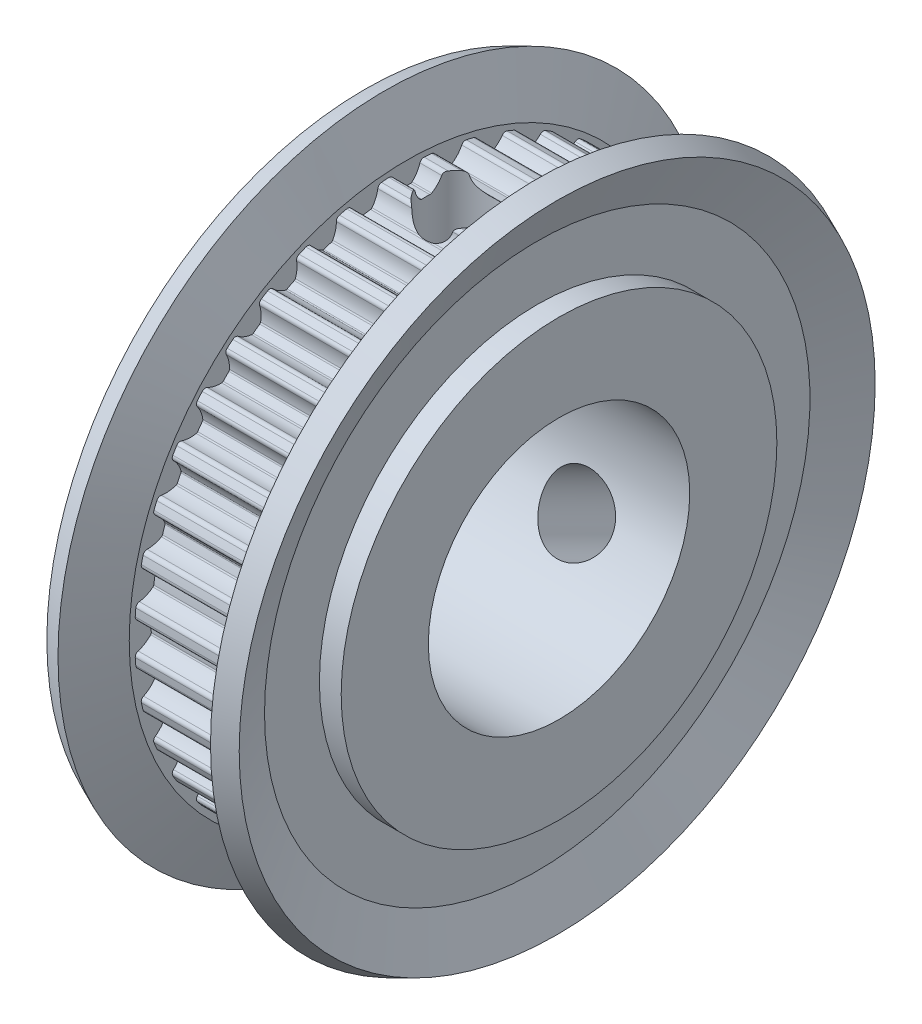
from build123d import *

# Parameters (mm, degrees)
SKETCH2_W           = 9
SKETCH2_H           = 15
CUT_EXTRUDE1_DEPTH  = 5
CUT_EXTRUDE2_DEPTH  = 5
CUT_EXTRUDE3_DEPTH  = 5
CUT_EXTRUDE4_DEPTH  = 5
CUT_EXTRUDE5_DEPTH  = 5
CUT_EXTRUDE6_DEPTH  = 5
CUT_EXTRUDE7_DEPTH  = 5
CUT_EXTRUDE8_DEPTH  = 5
CUT_EXTRUDE9_DEPTH  = 5
CUT_EXTRUDE10_DEPTH = 5
CUT_EXTRUDE11_DEPTH = 5
CUT_EXTRUDE12_DEPTH = 5
CUT_EXTRUDE13_DEPTH = 5
CUT_EXTRUDE14_DEPTH = 5
CUT_EXTRUDE15_DEPTH = 5
CUT_EXTRUDE16_DEPTH = 5
CUT_EXTRUDE17_DEPTH = 5
CUT_EXTRUDE18_DEPTH = 5
CUT_EXTRUDE19_DEPTH = 5
CUT_EXTRUDE20_DEPTH = 5
CUT_EXTRUDE21_DEPTH = 5
CUT_EXTRUDE22_DEPTH = 5
CUT_EXTRUDE23_DEPTH = 5
CUT_EXTRUDE24_DEPTH = 5
CUT_EXTRUDE25_DEPTH = 5
CUT_EXTRUDE26_DEPTH = 5
CUT_EXTRUDE27_DEPTH = 5
CUT_EXTRUDE28_DEPTH = 5
CUT_EXTRUDE29_DEPTH = 5
CUT_EXTRUDE30_DEPTH = 5
CUT_EXTRUDE31_DEPTH = 5
CUT_EXTRUDE32_DEPTH = 5
CUT_EXTRUDE33_DEPTH = 5
CUT_EXTRUDE34_DEPTH = 5
CUT_EXTRUDE35_DEPTH = 5
CUT_EXTRUDE36_DEPTH = 5
CUT_EXTRUDE37_DEPTH = 5
CUT_EXTRUDE38_DEPTH = 5
CUT_EXTRUDE39_DEPTH = 5
CUT_EXTRUDE40_DEPTH = 5
SKETCH43_W          = 1.621
SKETCH43_H          = 6.98


with BuildPart() as part:
    # Sketch1 → Revolve1 (revolve)
    with BuildSketch(Plane.XY):
        Polygon((0, 10), (0, 6), (17, 6), (17, 7), (9, 7), (9, 10), (8, 10), (8, 12.519496019), (8.915136608, 14.59685612), (8, 15), (7, 12.73), (7, 12.48), (2, 12.48), (2, 12.73), (1, 15), (0.084863392, 14.59685612), (1, 12.519496019), (1, 10), align=None)
    revolve(axis=Axis((17, 0, 0), (-1, 0, 0)))

    # Sketch2 → Cut-Revolve1 (revolve, cut)
    with BuildSketch(Plane.XY):
        with Locations((13.5, 7.5)):
            Rectangle(SKETCH2_W, SKETCH2_H)
    revolve(axis=Axis((18, 0, 0), (-1, 0, 0)), mode=Mode.SUBTRACT)

    # Sketch3 → Cut-Extrude1 (cut)
    with BuildSketch(Plane(origin=(2, 0, 0), x_dir=(0, 0, -1), z_dir=(1, 0, 0))):
        with BuildLine():
            Line((0.809176121, 12.45373976), (0.809176121, 16.64))
            Line((0.809176121, 16.64), (-0.809176121, 16.64))
            Line((-0.809176121, 16.64), (-0.809176121, 12.45373976))
            ThreePointArc((-0.809176121, 12.45373976), (-0.689195101, 12.420692836), (-0.615402928, 12.320481761))
            ThreePointArc((-0.615402928, 12.320481761), (-0.472569174, 12.009502865), (-0.254854193, 11.745477217))
            ThreePointArc((-0.254854193, 11.745477217), (-0.222536107, 11.725221856), (-0.18498492, 11.718540036))
            ThreePointArc((-0.18498492, 11.718540036), (1.1e-08, 11.72), (0.184984941, 11.718540036))
            ThreePointArc((0.184984941, 11.718540036), (0.222536138, 11.725221868), (0.254854227, 11.745477248))
            ThreePointArc((0.254854227, 11.745477248), (0.472569186, 12.009502884), (0.615402928, 12.320481761))
            ThreePointArc((0.615402928, 12.320481761), (0.689195101, 12.420692836), (0.809176121, 12.45373976))
        make_face()
    extrude(amount=CUT_EXTRUDE1_DEPTH, mode=Mode.SUBTRACT)

    # Sketch4 → Cut-Extrude2 (cut)
    with BuildSketch(Plane(origin=(2, 0, 0), x_dir=(0, 0, -1), z_dir=(1, 0, 0))):
        with BuildLine():
            Line((-1.148980297, 12.426996591), (-1.803855678, 16.561717021))
            Line((-1.803855678, 16.561717021), (-3.402283318, 16.308550954))
            Line((-3.402283318, 16.308550954), (-2.747407937, 12.173830524))
            ThreePointArc((-2.747407937, 12.173830524), (-2.623734404, 12.15995963), (-2.53517427, 12.072525958))
            ThreePointArc((-2.53517427, 12.072525958), (-2.345451219, 11.78771985), (-2.08911396, 11.561002923))
            ThreePointArc((-2.08911396, 11.561002923), (-2.054025127, 11.546052601), (-2.01589099, 11.545327346))
            ThreePointArc((-2.01589099, 11.545327346), (-1.83341192, 11.575707353), (-1.650476072, 11.603203382))
            ThreePointArc((-1.650476072, 11.603203382), (-1.614432461, 11.615677252), (-1.585680902, 11.640738917))
            ThreePointArc((-1.585680902, 11.640738917), (-1.411949084, 11.935572083), (-1.319521676, 12.265066414))
            ThreePointArc((-1.319521676, 12.265066414), (-1.262314474, 12.375587363), (-1.148980297, 12.426996591))
        make_face()
    extrude(amount=CUT_EXTRUDE2_DEPTH, mode=Mode.SUBTRACT)

    # Sketch5 → Cut-Extrude3 (cut)
    with BuildSketch(Plane(origin=(2, 0, 0), x_dir=(0, 0, -1), z_dir=(1, 0, 0))):
        with BuildLine():
            Line((-3.078845007, 12.094259524), (-4.372470564, 16.075629604))
            Line((-4.372470564, 16.075629604), (-5.911615009, 15.575531258))
            Line((-5.911615009, 15.575531258), (-4.617989452, 11.594161178))
            ThreePointArc((-4.617989452, 11.594161178), (-4.49366866, 11.59980786), (-4.392521208, 11.527304499))
            ThreePointArc((-4.392521208, 11.527304499), (-4.160580471, 11.275684051), (-3.871932808, 11.091858367))
            ThreePointArc((-3.871932808, 11.091858367), (-3.834937231, 11.082581212), (-3.797159134, 11.087830379))
            ThreePointArc((-3.797159134, 11.087830379), (-3.621679164, 11.146382374), (-3.445296887, 11.202157353))
            ThreePointArc((-3.445296887, 11.202157353), (-3.411648376, 11.220116111), (-3.387171304, 11.249366961))
            ThreePointArc((-3.387171304, 11.249366961), (-3.261700482, 11.567747885), (-3.221955278, 11.907644426))
            ThreePointArc((-3.221955278, 11.907644426), (-3.182741677, 12.025753857), (-3.078845007, 12.094259524))
        make_face()
    extrude(amount=CUT_EXTRUDE3_DEPTH, mode=Mode.SUBTRACT)

    # Sketch6 → Cut-Extrude4 (cut)
    with BuildSketch(Plane(origin=(2, 0, 0), x_dir=(0, 0, -1), z_dir=(1, 0, 0))):
        with BuildLine():
            Line((-4.932898334, 11.463721648), (-6.833420713, 15.193706834))
            Line((-6.833420713, 15.193706834), (-8.275383118, 14.458990291))
            Line((-8.275383118, 14.458990291), (-6.37486074, 10.729005105))
            ThreePointArc((-6.37486074, 10.729005105), (-6.252953879, 10.754030324), (-6.141709696, 10.698242547))
            ThreePointArc((-6.141709696, 10.698242547), (-5.873262424, 10.486003489), (-5.55941182, 10.349595447))
            ThreePointArc((-5.55941182, 10.349595447), (-5.521420453, 10.346219893), (-5.484928618, 10.35731423))
            ThreePointArc((-5.484928618, 10.35731423), (-5.320768648, 10.442596468), (-5.155283058, 10.525277032))
            ThreePointArc((-5.155283058, 10.525277032), (-5.124858184, 10.548278474), (-5.105258307, 10.580998256))
            ThreePointArc((-5.105258307, 10.580998256), (-5.031137988, 10.915087343), (-5.045053648, 11.257016713))
            ThreePointArc((-5.045053648, 11.257016713), (-5.024799217, 11.37980638), (-4.932898334, 11.463721648))
        make_face()
    extrude(amount=CUT_EXTRUDE4_DEPTH, mode=Mode.SUBTRACT)

    # Sketch7 → Cut-Extrude5 (cut)
    with BuildSketch(Plane(origin=(2, 0, 0), x_dir=(0, 0, -1), z_dir=(1, 0, 0))):
        with BuildLine():
            Line((-6.665487334, 10.550908899), (-9.126109365, 13.937664577))
            Line((-9.126109365, 13.937664577), (-10.435383831, 12.986420996))
            Line((-10.435383831, 12.986420996), (-7.9747618, 9.599665319))
            ThreePointArc((-7.9747618, 9.599665319), (-7.858270621, 9.64345287), (-7.739668907, 9.605754358))
            ThreePointArc((-7.739668907, 9.605754358), (-7.441325164, 9.438122721), (-7.109999663, 9.352491139))
            ThreePointArc((-7.109999663, 9.352491139), (-7.071947979, 9.355100302), (-7.037640956, 9.371766631))
            ThreePointArc((-7.037640956, 9.371766631), (-6.888843148, 9.48167918), (-6.73832905, 9.589229459))
            ThreePointArc((-6.73832905, 9.589229459), (-6.711876976, 9.616707214), (-6.697636907, 9.652090257))
            ThreePointArc((-6.697636907, 9.652090257), (-6.67669218, 9.993661125), (-6.743926053, 10.329203889))
            ThreePointArc((-6.743926053, 10.329203889), (-6.743129524, 10.453650303), (-6.665487334, 10.550908899))
        make_face()
    extrude(amount=CUT_EXTRUDE5_DEPTH, mode=Mode.SUBTRACT)

    # Sketch8 → Cut-Extrude6 (cut)
    with BuildSketch(Plane(origin=(2, 0, 0), x_dir=(0, 0, -1), z_dir=(1, 0, 0))):
        with BuildLine():
            Line((-8.233949913, 9.378297757), (-11.194082917, 12.338430761))
            Line((-11.194082917, 12.338430761), (-12.338430761, 11.194082917))
            Line((-12.338430761, 11.194082917), (-9.378297757, 8.233949913))
            ThreePointArc((-9.378297757, 8.233949913), (-9.270090661, 8.295421602), (-9.147051784, 8.276740617))
            ThreePointArc((-9.147051784, 8.276740617), (-8.826157782, 8.157844047), (-8.485515717, 8.12509746))
            ThreePointArc((-8.485515717, 8.12509746), (-8.448340676, 8.133627095), (-8.417063217, 8.155455034))
            ThreePointArc((-8.417063217, 8.155455034), (-8.287291468, 8.287291483), (-8.155455019, 8.417063231))
            ThreePointArc((-8.155455019, 8.417063231), (-8.133627081, 8.448340706), (-8.125097458, 8.485515762))
            ThreePointArc((-8.125097458, 8.485515762), (-8.157844052, 8.826157804), (-8.276740617, 9.147051784))
            ThreePointArc((-8.276740617, 9.147051784), (-8.295421602, 9.270090661), (-8.233949913, 9.378297757))
        make_face()
    extrude(amount=CUT_EXTRUDE6_DEPTH, mode=Mode.SUBTRACT)

    # Sketch9 → Cut-Extrude7 (cut)
    with BuildSketch(Plane(origin=(2, 0, 0), x_dir=(0, 0, -1), z_dir=(1, 0, 0))):
        with BuildLine():
            Line((-9.599665319, 7.9747618), (-12.986420996, 10.435383831))
            Line((-12.986420996, 10.435383831), (-13.937664577, 9.126109365))
            Line((-13.937664577, 9.126109365), (-10.550908899, 6.665487334))
            ThreePointArc((-10.550908899, 6.665487334), (-10.453650303, 6.743129524), (-10.329203889, 6.743926053))
            ThreePointArc((-10.329203889, 6.743926053), (-9.993661103, 6.676692179), (-9.652090212, 6.697636916))
            ThreePointArc((-9.652090212, 6.697636916), (-9.616707186, 6.711876994), (-9.589229446, 6.738329068))
            ThreePointArc((-9.589229446, 6.738329068), (-9.481679168, 6.888843165), (-9.371766618, 7.037640973))
            ThreePointArc((-9.371766618, 7.037640973), (-9.355100294, 7.071948011), (-9.352491145, 7.109999708))
            ThreePointArc((-9.352491145, 7.109999708), (-9.438122729, 7.441325185), (-9.605754358, 7.739668907))
            ThreePointArc((-9.605754358, 7.739668907), (-9.64345287, 7.858270621), (-9.599665319, 7.9747618))
        make_face()
    extrude(amount=CUT_EXTRUDE7_DEPTH, mode=Mode.SUBTRACT)

    # Sketch10 → Cut-Extrude8 (cut)
    with BuildSketch(Plane(origin=(2, 0, 0), x_dir=(0, 0, -1), z_dir=(1, 0, 0))):
        with BuildLine():
            Line((-10.729005105, 6.37486074), (-14.458990291, 8.275383118))
            Line((-14.458990291, 8.275383118), (-15.193706834, 6.833420713))
            Line((-15.193706834, 6.833420713), (-11.463721648, 4.932898334))
            ThreePointArc((-11.463721648, 4.932898334), (-11.37980638, 5.024799217), (-11.257016713, 5.045053648))
            ThreePointArc((-11.257016713, 5.045053648), (-10.91508732, 5.03113799), (-10.580998213, 5.105258322))
            ThreePointArc((-10.580998213, 5.105258322), (-10.54827845, 5.124858207), (-10.525277022, 5.155283077))
            ThreePointArc((-10.525277022, 5.155283077), (-10.442596459, 5.320768666), (-10.35731422, 5.484928636))
            ThreePointArc((-10.35731422, 5.484928636), (-10.346219889, 5.521420486), (-10.34959546, 5.559411864))
            ThreePointArc((-10.34959546, 5.559411864), (-10.486003501, 5.873262444), (-10.698242547, 6.141709696))
            ThreePointArc((-10.698242547, 6.141709696), (-10.754030324, 6.252953879), (-10.729005105, 6.37486074))
        make_face()
    extrude(amount=CUT_EXTRUDE8_DEPTH, mode=Mode.SUBTRACT)

    # Sketch11 → Cut-Extrude9 (cut)
    with BuildSketch(Plane(origin=(2, 0, 0), x_dir=(0, 0, -1), z_dir=(1, 0, 0))):
        with BuildLine():
            Line((-11.594161178, 4.617989452), (-15.575531258, 5.911615009))
            Line((-15.575531258, 5.911615009), (-16.075629604, 4.372470564))
            Line((-16.075629604, 4.372470564), (-12.094259524, 3.078845007))
            ThreePointArc((-12.094259524, 3.078845007), (-12.025753857, 3.182741677), (-11.907644426, 3.221955278))
            ThreePointArc((-11.907644426, 3.221955278), (-11.567747863, 3.261700487), (-11.249366921, 3.387171326))
            ThreePointArc((-11.249366921, 3.387171326), (-11.22011609, 3.411648402), (-11.202157347, 3.445296907))
            ThreePointArc((-11.202157347, 3.445296907), (-11.146382368, 3.621679184), (-11.087830372, 3.797159154))
            ThreePointArc((-11.087830372, 3.797159154), (-11.082581214, 3.834937264), (-11.091858387, 3.87193285))
            ThreePointArc((-11.091858387, 3.87193285), (-11.275684066, 4.160580489), (-11.527304499, 4.392521208))
            ThreePointArc((-11.527304499, 4.392521208), (-11.59980786, 4.49366866), (-11.594161178, 4.617989452))
        make_face()
    extrude(amount=CUT_EXTRUDE9_DEPTH, mode=Mode.SUBTRACT)

    # Sketch12 → Cut-Extrude10 (cut)
    with BuildSketch(Plane(origin=(2, 0, 0), x_dir=(0, 0, -1), z_dir=(1, 0, 0))):
        with BuildLine():
            Line((-12.173830524, 2.747407937), (-16.308550954, 3.402283318))
            Line((-16.308550954, 3.402283318), (-16.561717021, 1.803855678))
            Line((-16.561717021, 1.803855678), (-12.426996591, 1.148980297))
            ThreePointArc((-12.426996591, 1.148980297), (-12.375587363, 1.262314474), (-12.265066414, 1.319521676))
            ThreePointArc((-12.265066414, 1.319521676), (-11.935572062, 1.411949093), (-11.640738881, 1.58568093))
            ThreePointArc((-11.640738881, 1.58568093), (-11.615677235, 1.61443249), (-11.60320338, 1.650476093))
            ThreePointArc((-11.60320338, 1.650476093), (-11.57570735, 1.833411941), (-11.545327342, 2.015891011))
            ThreePointArc((-11.545327342, 2.015891011), (-11.546052608, 2.054025159), (-11.561002948, 2.089113998))
            ThreePointArc((-11.561002948, 2.089113998), (-11.787719867, 2.345451234), (-12.072525958, 2.53517427))
            ThreePointArc((-12.072525958, 2.53517427), (-12.15995963, 2.623734404), (-12.173830524, 2.747407937))
        make_face()
    extrude(amount=CUT_EXTRUDE10_DEPTH, mode=Mode.SUBTRACT)

    # Sketch13 → Cut-Extrude11 (cut)
    with BuildSketch(Plane(origin=(2, 0, 0), x_dir=(0, 0, -1), z_dir=(1, 0, 0))):
        with BuildLine():
            Line((-12.45373976, 0.809176121), (-16.64, 0.809176121))
            Line((-16.64, 0.809176121), (-16.64, -0.809176121))
            Line((-16.64, -0.809176121), (-12.45373976, -0.809176121))
            ThreePointArc((-12.45373976, -0.809176121), (-12.420692836, -0.689195101), (-12.320481761, -0.615402928))
            ThreePointArc((-12.320481761, -0.615402928), (-12.009502865, -0.472569174), (-11.745477217, -0.254854193))
            ThreePointArc((-11.745477217, -0.254854193), (-11.725221856, -0.222536107), (-11.718540036, -0.18498492))
            ThreePointArc((-11.718540036, -0.18498492), (-11.72, 1.1e-08), (-11.718540036, 0.184984941))
            ThreePointArc((-11.718540036, 0.184984941), (-11.725221868, 0.222536138), (-11.745477248, 0.254854227))
            ThreePointArc((-11.745477248, 0.254854227), (-12.009502884, 0.472569186), (-12.320481761, 0.615402928))
            ThreePointArc((-12.320481761, 0.615402928), (-12.420692836, 0.689195101), (-12.45373976, 0.809176121))
        make_face()
    extrude(amount=CUT_EXTRUDE11_DEPTH, mode=Mode.SUBTRACT)

    # Sketch14 → Cut-Extrude12 (cut)
    with BuildSketch(Plane(origin=(2, 0, 0), x_dir=(0, 0, -1), z_dir=(1, 0, 0))):
        with BuildLine():
            Line((-12.426996591, -1.148980297), (-16.561717021, -1.803855678))
            Line((-16.561717021, -1.803855678), (-16.308550954, -3.402283318))
            Line((-16.308550954, -3.402283318), (-12.173830524, -2.747407937))
            ThreePointArc((-12.173830524, -2.747407937), (-12.15995963, -2.623734404), (-12.072525958, -2.53517427))
            ThreePointArc((-12.072525958, -2.53517427), (-11.78771985, -2.345451219), (-11.561002923, -2.08911396))
            ThreePointArc((-11.561002923, -2.08911396), (-11.546052601, -2.054025127), (-11.545327346, -2.01589099))
            ThreePointArc((-11.545327346, -2.01589099), (-11.575707353, -1.83341192), (-11.603203382, -1.650476072))
            ThreePointArc((-11.603203382, -1.650476072), (-11.615677252, -1.614432461), (-11.640738917, -1.585680902))
            ThreePointArc((-11.640738917, -1.585680902), (-11.935572083, -1.411949084), (-12.265066414, -1.319521676))
            ThreePointArc((-12.265066414, -1.319521676), (-12.375587363, -1.262314474), (-12.426996591, -1.148980297))
        make_face()
    extrude(amount=CUT_EXTRUDE12_DEPTH, mode=Mode.SUBTRACT)

    # Sketch15 → Cut-Extrude13 (cut)
    with BuildSketch(Plane(origin=(2, 0, 0), x_dir=(0, 0, -1), z_dir=(1, 0, 0))):
        with BuildLine():
            Line((-12.094259524, -3.078845007), (-16.075629604, -4.372470564))
            Line((-16.075629604, -4.372470564), (-15.575531258, -5.911615009))
            Line((-15.575531258, -5.911615009), (-11.594161178, -4.617989452))
            ThreePointArc((-11.594161178, -4.617989452), (-11.59980786, -4.49366866), (-11.527304499, -4.392521208))
            ThreePointArc((-11.527304499, -4.392521208), (-11.275684051, -4.160580471), (-11.091858367, -3.871932808))
            ThreePointArc((-11.091858367, -3.871932808), (-11.082581212, -3.834937231), (-11.087830379, -3.797159134))
            ThreePointArc((-11.087830379, -3.797159134), (-11.146382374, -3.621679164), (-11.202157353, -3.445296887))
            ThreePointArc((-11.202157353, -3.445296887), (-11.220116111, -3.411648376), (-11.249366961, -3.387171304))
            ThreePointArc((-11.249366961, -3.387171304), (-11.567747885, -3.261700482), (-11.907644426, -3.221955278))
            ThreePointArc((-11.907644426, -3.221955278), (-12.025753857, -3.182741677), (-12.094259524, -3.078845007))
        make_face()
    extrude(amount=CUT_EXTRUDE13_DEPTH, mode=Mode.SUBTRACT)

    # Sketch16 → Cut-Extrude14 (cut)
    with BuildSketch(Plane(origin=(2, 0, 0), x_dir=(0, 0, -1), z_dir=(1, 0, 0))):
        with BuildLine():
            Line((-11.463721648, -4.932898334), (-15.193706834, -6.833420713))
            Line((-15.193706834, -6.833420713), (-14.458990291, -8.275383118))
            Line((-14.458990291, -8.275383118), (-10.729005105, -6.37486074))
            ThreePointArc((-10.729005105, -6.37486074), (-10.754030324, -6.252953879), (-10.698242547, -6.141709696))
            ThreePointArc((-10.698242547, -6.141709696), (-10.486003489, -5.873262424), (-10.349595447, -5.55941182))
            ThreePointArc((-10.349595447, -5.55941182), (-10.346219893, -5.521420453), (-10.35731423, -5.484928618))
            ThreePointArc((-10.35731423, -5.484928618), (-10.442596468, -5.320768648), (-10.525277032, -5.155283058))
            ThreePointArc((-10.525277032, -5.155283058), (-10.548278474, -5.124858184), (-10.580998256, -5.105258307))
            ThreePointArc((-10.580998256, -5.105258307), (-10.915087343, -5.031137988), (-11.257016713, -5.045053648))
            ThreePointArc((-11.257016713, -5.045053648), (-11.37980638, -5.024799217), (-11.463721648, -4.932898334))
        make_face()
    extrude(amount=CUT_EXTRUDE14_DEPTH, mode=Mode.SUBTRACT)

    # Sketch17 → Cut-Extrude15 (cut)
    with BuildSketch(Plane(origin=(2, 0, 0), x_dir=(0, 0, -1), z_dir=(1, 0, 0))):
        with BuildLine():
            Line((-10.550908899, -6.665487334), (-13.937664577, -9.126109365))
            Line((-13.937664577, -9.126109365), (-12.986420996, -10.435383831))
            Line((-12.986420996, -10.435383831), (-9.599665319, -7.9747618))
            ThreePointArc((-9.599665319, -7.9747618), (-9.64345287, -7.858270621), (-9.605754358, -7.739668907))
            ThreePointArc((-9.605754358, -7.739668907), (-9.438122721, -7.441325164), (-9.352491139, -7.109999663))
            ThreePointArc((-9.352491139, -7.109999663), (-9.355100302, -7.071947979), (-9.371766631, -7.037640956))
            ThreePointArc((-9.371766631, -7.037640956), (-9.48167918, -6.888843148), (-9.589229459, -6.73832905))
            ThreePointArc((-9.589229459, -6.73832905), (-9.616707214, -6.711876976), (-9.652090257, -6.697636907))
            ThreePointArc((-9.652090257, -6.697636907), (-9.993661125, -6.67669218), (-10.329203889, -6.743926053))
            ThreePointArc((-10.329203889, -6.743926053), (-10.453650303, -6.743129524), (-10.550908899, -6.665487334))
        make_face()
    extrude(amount=CUT_EXTRUDE15_DEPTH, mode=Mode.SUBTRACT)

    # Sketch18 → Cut-Extrude16 (cut)
    with BuildSketch(Plane(origin=(2, 0, 0), x_dir=(0, 0, -1), z_dir=(1, 0, 0))):
        with BuildLine():
            Line((-9.378297757, -8.233949913), (-12.338430761, -11.194082917))
            Line((-12.338430761, -11.194082917), (-11.194082917, -12.338430761))
            Line((-11.194082917, -12.338430761), (-8.233949913, -9.378297757))
            ThreePointArc((-8.233949913, -9.378297757), (-8.295421602, -9.270090661), (-8.276740617, -9.147051784))
            ThreePointArc((-8.276740617, -9.147051784), (-8.157844047, -8.826157782), (-8.12509746, -8.485515717))
            ThreePointArc((-8.12509746, -8.485515717), (-8.133627095, -8.448340676), (-8.155455034, -8.417063217))
            ThreePointArc((-8.155455034, -8.417063217), (-8.287291483, -8.287291468), (-8.417063231, -8.155455019))
            ThreePointArc((-8.417063231, -8.155455019), (-8.448340706, -8.133627081), (-8.485515762, -8.125097458))
            ThreePointArc((-8.485515762, -8.125097458), (-8.826157804, -8.157844052), (-9.147051784, -8.276740617))
            ThreePointArc((-9.147051784, -8.276740617), (-9.270090661, -8.295421602), (-9.378297757, -8.233949913))
        make_face()
    extrude(amount=CUT_EXTRUDE16_DEPTH, mode=Mode.SUBTRACT)

    # Sketch19 → Cut-Extrude17 (cut)
    with BuildSketch(Plane(origin=(2, 0, 0), x_dir=(0, 0, -1), z_dir=(1, 0, 0))):
        with BuildLine():
            Line((-7.9747618, -9.599665319), (-10.435383831, -12.986420996))
            Line((-10.435383831, -12.986420996), (-9.126109365, -13.937664577))
            Line((-9.126109365, -13.937664577), (-6.665487334, -10.550908899))
            ThreePointArc((-6.665487334, -10.550908899), (-6.743129524, -10.453650303), (-6.743926053, -10.329203889))
            ThreePointArc((-6.743926053, -10.329203889), (-6.676692179, -9.993661103), (-6.697636916, -9.652090212))
            ThreePointArc((-6.697636916, -9.652090212), (-6.711876994, -9.616707186), (-6.738329068, -9.589229446))
            ThreePointArc((-6.738329068, -9.589229446), (-6.888843165, -9.481679168), (-7.037640973, -9.371766618))
            ThreePointArc((-7.037640973, -9.371766618), (-7.071948011, -9.355100294), (-7.109999708, -9.352491145))
            ThreePointArc((-7.109999708, -9.352491145), (-7.441325185, -9.438122729), (-7.739668907, -9.605754358))
            ThreePointArc((-7.739668907, -9.605754358), (-7.858270621, -9.64345287), (-7.9747618, -9.599665319))
        make_face()
    extrude(amount=CUT_EXTRUDE17_DEPTH, mode=Mode.SUBTRACT)

    # Sketch20 → Cut-Extrude18 (cut)
    with BuildSketch(Plane(origin=(2, 0, 0), x_dir=(0, 0, -1), z_dir=(1, 0, 0))):
        with BuildLine():
            Line((-6.37486074, -10.729005105), (-8.275383118, -14.458990291))
            Line((-8.275383118, -14.458990291), (-6.833420713, -15.193706834))
            Line((-6.833420713, -15.193706834), (-4.932898334, -11.463721648))
            ThreePointArc((-4.932898334, -11.463721648), (-5.024799217, -11.37980638), (-5.045053648, -11.257016713))
            ThreePointArc((-5.045053648, -11.257016713), (-5.03113799, -10.91508732), (-5.105258322, -10.580998213))
            ThreePointArc((-5.105258322, -10.580998213), (-5.124858207, -10.54827845), (-5.155283077, -10.525277022))
            ThreePointArc((-5.155283077, -10.525277022), (-5.320768666, -10.442596459), (-5.484928636, -10.35731422))
            ThreePointArc((-5.484928636, -10.35731422), (-5.521420486, -10.346219889), (-5.559411864, -10.34959546))
            ThreePointArc((-5.559411864, -10.34959546), (-5.873262444, -10.486003501), (-6.141709696, -10.698242547))
            ThreePointArc((-6.141709696, -10.698242547), (-6.252953879, -10.754030324), (-6.37486074, -10.729005105))
        make_face()
    extrude(amount=CUT_EXTRUDE18_DEPTH, mode=Mode.SUBTRACT)

    # Sketch21 → Cut-Extrude19 (cut)
    with BuildSketch(Plane(origin=(2, 0, 0), x_dir=(0, 0, -1), z_dir=(1, 0, 0))):
        with BuildLine():
            Line((-4.617989452, -11.594161178), (-5.911615009, -15.575531258))
            Line((-5.911615009, -15.575531258), (-4.372470564, -16.075629604))
            Line((-4.372470564, -16.075629604), (-3.078845007, -12.094259524))
            ThreePointArc((-3.078845007, -12.094259524), (-3.182741677, -12.025753857), (-3.221955278, -11.907644426))
            ThreePointArc((-3.221955278, -11.907644426), (-3.261700487, -11.567747863), (-3.387171326, -11.249366921))
            ThreePointArc((-3.387171326, -11.249366921), (-3.411648402, -11.22011609), (-3.445296907, -11.202157347))
            ThreePointArc((-3.445296907, -11.202157347), (-3.621679184, -11.146382368), (-3.797159154, -11.087830372))
            ThreePointArc((-3.797159154, -11.087830372), (-3.834937264, -11.082581214), (-3.87193285, -11.091858387))
            ThreePointArc((-3.87193285, -11.091858387), (-4.160580489, -11.275684066), (-4.392521208, -11.527304499))
            ThreePointArc((-4.392521208, -11.527304499), (-4.49366866, -11.59980786), (-4.617989452, -11.594161178))
        make_face()
    extrude(amount=CUT_EXTRUDE19_DEPTH, mode=Mode.SUBTRACT)

    # Sketch22 → Cut-Extrude20 (cut)
    with BuildSketch(Plane(origin=(2, 0, 0), x_dir=(0, 0, -1), z_dir=(1, 0, 0))):
        with BuildLine():
            Line((-2.747407937, -12.173830524), (-3.402283318, -16.308550954))
            Line((-3.402283318, -16.308550954), (-1.803855678, -16.561717021))
            Line((-1.803855678, -16.561717021), (-1.148980297, -12.426996591))
            ThreePointArc((-1.148980297, -12.426996591), (-1.262314474, -12.375587363), (-1.319521676, -12.265066414))
            ThreePointArc((-1.319521676, -12.265066414), (-1.411949093, -11.935572062), (-1.58568093, -11.640738881))
            ThreePointArc((-1.58568093, -11.640738881), (-1.61443249, -11.615677235), (-1.650476093, -11.60320338))
            ThreePointArc((-1.650476093, -11.60320338), (-1.833411941, -11.57570735), (-2.015891011, -11.545327342))
            ThreePointArc((-2.015891011, -11.545327342), (-2.054025159, -11.546052608), (-2.089113998, -11.561002948))
            ThreePointArc((-2.089113998, -11.561002948), (-2.345451234, -11.787719867), (-2.53517427, -12.072525958))
            ThreePointArc((-2.53517427, -12.072525958), (-2.623734404, -12.15995963), (-2.747407937, -12.173830524))
        make_face()
    extrude(amount=CUT_EXTRUDE20_DEPTH, mode=Mode.SUBTRACT)

    # Sketch23 → Cut-Extrude21 (cut)
    with BuildSketch(Plane(origin=(2, 0, 0), x_dir=(0, 0, -1), z_dir=(1, 0, 0))):
        with BuildLine():
            Line((-0.809176132, -12.453739748), (-0.809176194, -16.639999988))
            Line((-0.809176194, -16.639999988), (0.809176047, -16.640000012))
            Line((0.809176047, -16.640000012), (0.80917611, -12.453739772))
            ThreePointArc((0.80917611, -12.453739772), (0.68919509, -12.420692847), (0.615402919, -12.32048177))
            ThreePointArc((0.615402919, -12.32048177), (0.472569169, -12.009502872), (0.254854193, -11.745477221))
            ThreePointArc((0.254854193, -11.745477221), (0.222536107, -11.725221859), (0.18498492, -11.718540039))
            ThreePointArc((0.18498492, -11.718540039), (-1.1e-08, -11.72), (-0.184984941, -11.718540033))
            ThreePointArc((-0.184984941, -11.718540033), (-0.222536138, -11.725221865), (-0.254854227, -11.745477244))
            ThreePointArc((-0.254854227, -11.745477244), (-0.47256919, -12.009502877), (-0.615402937, -12.320481752))
            ThreePointArc((-0.615402937, -12.320481752), (-0.689195111, -12.420692826), (-0.809176132, -12.453739748))
        make_face()
    extrude(amount=CUT_EXTRUDE21_DEPTH, mode=Mode.SUBTRACT)

    # Sketch24 → Cut-Extrude22 (cut)
    with BuildSketch(Plane(origin=(2, 0, 0), x_dir=(0, 0, -1), z_dir=(1, 0, 0))):
        with BuildLine():
            Line((1.148980297, -12.426996591), (1.803855678, -16.561717021))
            Line((1.803855678, -16.561717021), (3.402283318, -16.308550954))
            Line((3.402283318, -16.308550954), (2.747407937, -12.173830524))
            ThreePointArc((2.747407937, -12.173830524), (2.623734404, -12.15995963), (2.53517427, -12.072525958))
            ThreePointArc((2.53517427, -12.072525958), (2.345451219, -11.78771985), (2.08911396, -11.561002923))
            ThreePointArc((2.08911396, -11.561002923), (2.054025127, -11.546052601), (2.01589099, -11.545327346))
            ThreePointArc((2.01589099, -11.545327346), (1.83341192, -11.575707353), (1.650476072, -11.603203382))
            ThreePointArc((1.650476072, -11.603203382), (1.614432461, -11.615677252), (1.585680902, -11.640738917))
            ThreePointArc((1.585680902, -11.640738917), (1.411949084, -11.935572083), (1.319521676, -12.265066414))
            ThreePointArc((1.319521676, -12.265066414), (1.262314474, -12.375587363), (1.148980297, -12.426996591))
        make_face()
    extrude(amount=CUT_EXTRUDE22_DEPTH, mode=Mode.SUBTRACT)

    # Sketch25 → Cut-Extrude23 (cut)
    with BuildSketch(Plane(origin=(2, 0, 0), x_dir=(0, 0, -1), z_dir=(1, 0, 0))):
        with BuildLine():
            Line((3.078845007, -12.094259524), (4.372470564, -16.075629604))
            Line((4.372470564, -16.075629604), (5.911615009, -15.575531258))
            Line((5.911615009, -15.575531258), (4.617989452, -11.594161178))
            ThreePointArc((4.617989452, -11.594161178), (4.49366866, -11.59980786), (4.392521208, -11.527304499))
            ThreePointArc((4.392521208, -11.527304499), (4.160580471, -11.275684051), (3.871932808, -11.091858367))
            ThreePointArc((3.871932808, -11.091858367), (3.834937231, -11.082581212), (3.797159134, -11.087830379))
            ThreePointArc((3.797159134, -11.087830379), (3.621679164, -11.146382374), (3.445296887, -11.202157353))
            ThreePointArc((3.445296887, -11.202157353), (3.411648376, -11.220116111), (3.387171304, -11.249366961))
            ThreePointArc((3.387171304, -11.249366961), (3.261700482, -11.567747885), (3.221955278, -11.907644426))
            ThreePointArc((3.221955278, -11.907644426), (3.182741677, -12.025753857), (3.078845007, -12.094259524))
        make_face()
    extrude(amount=CUT_EXTRUDE23_DEPTH, mode=Mode.SUBTRACT)

    # Sketch26 → Cut-Extrude24 (cut)
    with BuildSketch(Plane(origin=(2, 0, 0), x_dir=(0, 0, -1), z_dir=(1, 0, 0))):
        with BuildLine():
            Line((4.932898334, -11.463721648), (6.833420713, -15.193706834))
            Line((6.833420713, -15.193706834), (8.275383118, -14.458990291))
            Line((8.275383118, -14.458990291), (6.37486074, -10.729005105))
            ThreePointArc((6.37486074, -10.729005105), (6.252953879, -10.754030324), (6.141709696, -10.698242547))
            ThreePointArc((6.141709696, -10.698242547), (5.873262424, -10.486003489), (5.55941182, -10.349595447))
            ThreePointArc((5.55941182, -10.349595447), (5.521420453, -10.346219893), (5.484928618, -10.35731423))
            ThreePointArc((5.484928618, -10.35731423), (5.320768648, -10.442596468), (5.155283058, -10.525277032))
            ThreePointArc((5.155283058, -10.525277032), (5.124858184, -10.548278474), (5.105258307, -10.580998256))
            ThreePointArc((5.105258307, -10.580998256), (5.031137988, -10.915087343), (5.045053648, -11.257016713))
            ThreePointArc((5.045053648, -11.257016713), (5.024799217, -11.37980638), (4.932898334, -11.463721648))
        make_face()
    extrude(amount=CUT_EXTRUDE24_DEPTH, mode=Mode.SUBTRACT)

    # Sketch27 → Cut-Extrude25 (cut)
    with BuildSketch(Plane(origin=(2, 0, 0), x_dir=(0, 0, -1), z_dir=(1, 0, 0))):
        with BuildLine():
            Line((6.665487334, -10.550908899), (9.126109365, -13.937664577))
            Line((9.126109365, -13.937664577), (10.435383831, -12.986420996))
            Line((10.435383831, -12.986420996), (7.9747618, -9.599665319))
            ThreePointArc((7.9747618, -9.599665319), (7.858270621, -9.64345287), (7.739668907, -9.605754358))
            ThreePointArc((7.739668907, -9.605754358), (7.441325164, -9.438122721), (7.109999663, -9.352491139))
            ThreePointArc((7.109999663, -9.352491139), (7.071947979, -9.355100302), (7.037640956, -9.371766631))
            ThreePointArc((7.037640956, -9.371766631), (6.888843148, -9.48167918), (6.73832905, -9.589229459))
            ThreePointArc((6.73832905, -9.589229459), (6.711876976, -9.616707214), (6.697636907, -9.652090257))
            ThreePointArc((6.697636907, -9.652090257), (6.67669218, -9.993661125), (6.743926053, -10.329203889))
            ThreePointArc((6.743926053, -10.329203889), (6.743129524, -10.453650303), (6.665487334, -10.550908899))
        make_face()
    extrude(amount=CUT_EXTRUDE25_DEPTH, mode=Mode.SUBTRACT)

    # Sketch28 → Cut-Extrude26 (cut)
    with BuildSketch(Plane(origin=(2, 0, 0), x_dir=(0, 0, -1), z_dir=(1, 0, 0))):
        with BuildLine():
            Line((8.233949913, -9.378297757), (11.194082917, -12.338430761))
            Line((11.194082917, -12.338430761), (12.338430761, -11.194082917))
            Line((12.338430761, -11.194082917), (9.378297757, -8.233949913))
            ThreePointArc((9.378297757, -8.233949913), (9.270090661, -8.295421602), (9.147051784, -8.276740617))
            ThreePointArc((9.147051784, -8.276740617), (8.826157782, -8.157844047), (8.485515717, -8.12509746))
            ThreePointArc((8.485515717, -8.12509746), (8.448340676, -8.133627095), (8.417063217, -8.155455034))
            ThreePointArc((8.417063217, -8.155455034), (8.287291468, -8.287291483), (8.155455019, -8.417063231))
            ThreePointArc((8.155455019, -8.417063231), (8.133627081, -8.448340706), (8.125097458, -8.485515762))
            ThreePointArc((8.125097458, -8.485515762), (8.157844052, -8.826157804), (8.276740617, -9.147051784))
            ThreePointArc((8.276740617, -9.147051784), (8.295421602, -9.270090661), (8.233949913, -9.378297757))
        make_face()
    extrude(amount=CUT_EXTRUDE26_DEPTH, mode=Mode.SUBTRACT)

    # Sketch29 → Cut-Extrude27 (cut)
    with BuildSketch(Plane(origin=(2, 0, 0), x_dir=(0, 0, -1), z_dir=(1, 0, 0))):
        with BuildLine():
            Line((9.599665319, -7.9747618), (12.986420996, -10.435383831))
            Line((12.986420996, -10.435383831), (13.937664577, -9.126109365))
            Line((13.937664577, -9.126109365), (10.550908899, -6.665487334))
            ThreePointArc((10.550908899, -6.665487334), (10.453650303, -6.743129524), (10.329203889, -6.743926053))
            ThreePointArc((10.329203889, -6.743926053), (9.993661103, -6.676692179), (9.652090212, -6.697636916))
            ThreePointArc((9.652090212, -6.697636916), (9.616707186, -6.711876994), (9.589229446, -6.738329068))
            ThreePointArc((9.589229446, -6.738329068), (9.481679168, -6.888843165), (9.371766618, -7.037640973))
            ThreePointArc((9.371766618, -7.037640973), (9.355100294, -7.071948011), (9.352491145, -7.109999708))
            ThreePointArc((9.352491145, -7.109999708), (9.438122729, -7.441325185), (9.605754358, -7.739668907))
            ThreePointArc((9.605754358, -7.739668907), (9.64345287, -7.858270621), (9.599665319, -7.9747618))
        make_face()
    extrude(amount=CUT_EXTRUDE27_DEPTH, mode=Mode.SUBTRACT)

    # Sketch30 → Cut-Extrude28 (cut)
    with BuildSketch(Plane(origin=(2, 0, 0), x_dir=(0, 0, -1), z_dir=(1, 0, 0))):
        with BuildLine():
            Line((10.729005105, -6.37486074), (14.458990291, -8.275383118))
            Line((14.458990291, -8.275383118), (15.193706834, -6.833420713))
            Line((15.193706834, -6.833420713), (11.463721648, -4.932898334))
            ThreePointArc((11.463721648, -4.932898334), (11.37980638, -5.024799217), (11.257016713, -5.045053648))
            ThreePointArc((11.257016713, -5.045053648), (10.91508732, -5.03113799), (10.580998213, -5.105258322))
            ThreePointArc((10.580998213, -5.105258322), (10.54827845, -5.124858207), (10.525277022, -5.155283077))
            ThreePointArc((10.525277022, -5.155283077), (10.442596459, -5.320768666), (10.35731422, -5.484928636))
            ThreePointArc((10.35731422, -5.484928636), (10.346219889, -5.521420486), (10.34959546, -5.559411864))
            ThreePointArc((10.34959546, -5.559411864), (10.486003501, -5.873262444), (10.698242547, -6.141709696))
            ThreePointArc((10.698242547, -6.141709696), (10.754030324, -6.252953879), (10.729005105, -6.37486074))
        make_face()
    extrude(amount=CUT_EXTRUDE28_DEPTH, mode=Mode.SUBTRACT)

    # Sketch31 → Cut-Extrude29 (cut)
    with BuildSketch(Plane(origin=(2, 0, 0), x_dir=(0, 0, -1), z_dir=(1, 0, 0))):
        with BuildLine():
            Line((11.594161178, -4.617989452), (15.575531258, -5.911615009))
            Line((15.575531258, -5.911615009), (16.075629604, -4.372470564))
            Line((16.075629604, -4.372470564), (12.094259524, -3.078845007))
            ThreePointArc((12.094259524, -3.078845007), (12.025753857, -3.182741677), (11.907644426, -3.221955278))
            ThreePointArc((11.907644426, -3.221955278), (11.567747863, -3.261700487), (11.249366921, -3.387171326))
            ThreePointArc((11.249366921, -3.387171326), (11.22011609, -3.411648402), (11.202157347, -3.445296907))
            ThreePointArc((11.202157347, -3.445296907), (11.146382368, -3.621679184), (11.087830372, -3.797159154))
            ThreePointArc((11.087830372, -3.797159154), (11.082581214, -3.834937264), (11.091858387, -3.87193285))
            ThreePointArc((11.091858387, -3.87193285), (11.275684066, -4.160580489), (11.527304499, -4.392521208))
            ThreePointArc((11.527304499, -4.392521208), (11.59980786, -4.49366866), (11.594161178, -4.617989452))
        make_face()
    extrude(amount=CUT_EXTRUDE29_DEPTH, mode=Mode.SUBTRACT)

    # Sketch32 → Cut-Extrude30 (cut)
    with BuildSketch(Plane(origin=(2, 0, 0), x_dir=(0, 0, -1), z_dir=(1, 0, 0))):
        with BuildLine():
            Line((12.173830524, -2.747407937), (16.308550954, -3.402283318))
            Line((16.308550954, -3.402283318), (16.561717021, -1.803855678))
            Line((16.561717021, -1.803855678), (12.426996591, -1.148980297))
            ThreePointArc((12.426996591, -1.148980297), (12.375587363, -1.262314474), (12.265066414, -1.319521676))
            ThreePointArc((12.265066414, -1.319521676), (11.935572062, -1.411949093), (11.640738881, -1.58568093))
            ThreePointArc((11.640738881, -1.58568093), (11.615677235, -1.61443249), (11.60320338, -1.650476093))
            ThreePointArc((11.60320338, -1.650476093), (11.57570735, -1.833411941), (11.545327342, -2.015891011))
            ThreePointArc((11.545327342, -2.015891011), (11.546052608, -2.054025159), (11.561002948, -2.089113998))
            ThreePointArc((11.561002948, -2.089113998), (11.787719867, -2.345451234), (12.072525958, -2.53517427))
            ThreePointArc((12.072525958, -2.53517427), (12.15995963, -2.623734404), (12.173830524, -2.747407937))
        make_face()
    extrude(amount=CUT_EXTRUDE30_DEPTH, mode=Mode.SUBTRACT)

    # Sketch33 → Cut-Extrude31 (cut)
    with BuildSketch(Plane(origin=(2, 0, 0), x_dir=(0, 0, -1), z_dir=(1, 0, 0))):
        with BuildLine():
            Line((12.45373976, -0.809176121), (16.64, -0.809176121))
            Line((16.64, -0.809176121), (16.64, 0.809176121))
            Line((16.64, 0.809176121), (12.45373976, 0.809176121))
            ThreePointArc((12.45373976, 0.809176121), (12.420692836, 0.689195101), (12.320481761, 0.615402928))
            ThreePointArc((12.320481761, 0.615402928), (12.009502865, 0.472569174), (11.745477217, 0.254854193))
            ThreePointArc((11.745477217, 0.254854193), (11.725221856, 0.222536107), (11.718540036, 0.18498492))
            ThreePointArc((11.718540036, 0.18498492), (11.72, -1.1e-08), (11.718540036, -0.184984941))
            ThreePointArc((11.718540036, -0.184984941), (11.725221868, -0.222536138), (11.745477248, -0.254854227))
            ThreePointArc((11.745477248, -0.254854227), (12.009502884, -0.472569186), (12.320481761, -0.615402928))
            ThreePointArc((12.320481761, -0.615402928), (12.420692836, -0.689195101), (12.45373976, -0.809176121))
        make_face()
    extrude(amount=CUT_EXTRUDE31_DEPTH, mode=Mode.SUBTRACT)

    # Sketch34 → Cut-Extrude32 (cut)
    with BuildSketch(Plane(origin=(2, 0, 0), x_dir=(0, 0, -1), z_dir=(1, 0, 0))):
        with BuildLine():
            Line((12.426996591, 1.148980297), (16.561717021, 1.803855678))
            Line((16.561717021, 1.803855678), (16.308550954, 3.402283318))
            Line((16.308550954, 3.402283318), (12.173830524, 2.747407937))
            ThreePointArc((12.173830524, 2.747407937), (12.15995963, 2.623734404), (12.072525958, 2.53517427))
            ThreePointArc((12.072525958, 2.53517427), (11.78771985, 2.345451219), (11.561002923, 2.08911396))
            ThreePointArc((11.561002923, 2.08911396), (11.546052601, 2.054025127), (11.545327346, 2.01589099))
            ThreePointArc((11.545327346, 2.01589099), (11.575707353, 1.83341192), (11.603203382, 1.650476072))
            ThreePointArc((11.603203382, 1.650476072), (11.615677252, 1.614432461), (11.640738917, 1.585680902))
            ThreePointArc((11.640738917, 1.585680902), (11.935572083, 1.411949084), (12.265066414, 1.319521676))
            ThreePointArc((12.265066414, 1.319521676), (12.375587363, 1.262314474), (12.426996591, 1.148980297))
        make_face()
    extrude(amount=CUT_EXTRUDE32_DEPTH, mode=Mode.SUBTRACT)

    # Sketch35 → Cut-Extrude33 (cut)
    with BuildSketch(Plane(origin=(2, 0, 0), x_dir=(0, 0, -1), z_dir=(1, 0, 0))):
        with BuildLine():
            Line((12.094259524, 3.078845007), (16.075629604, 4.372470564))
            Line((16.075629604, 4.372470564), (15.575531258, 5.911615009))
            Line((15.575531258, 5.911615009), (11.594161178, 4.617989452))
            ThreePointArc((11.594161178, 4.617989452), (11.59980786, 4.49366866), (11.527304499, 4.392521208))
            ThreePointArc((11.527304499, 4.392521208), (11.275684051, 4.160580471), (11.091858367, 3.871932808))
            ThreePointArc((11.091858367, 3.871932808), (11.082581212, 3.834937231), (11.087830379, 3.797159134))
            ThreePointArc((11.087830379, 3.797159134), (11.146382374, 3.621679164), (11.202157353, 3.445296887))
            ThreePointArc((11.202157353, 3.445296887), (11.220116111, 3.411648376), (11.249366961, 3.387171304))
            ThreePointArc((11.249366961, 3.387171304), (11.567747885, 3.261700482), (11.907644426, 3.221955278))
            ThreePointArc((11.907644426, 3.221955278), (12.025753857, 3.182741677), (12.094259524, 3.078845007))
        make_face()
    extrude(amount=CUT_EXTRUDE33_DEPTH, mode=Mode.SUBTRACT)

    # Sketch36 → Cut-Extrude34 (cut)
    with BuildSketch(Plane(origin=(2, 0, 0), x_dir=(0, 0, -1), z_dir=(1, 0, 0))):
        with BuildLine():
            Line((11.463721648, 4.932898334), (15.193706834, 6.833420713))
            Line((15.193706834, 6.833420713), (14.458990291, 8.275383118))
            Line((14.458990291, 8.275383118), (10.729005105, 6.37486074))
            ThreePointArc((10.729005105, 6.37486074), (10.754030324, 6.252953879), (10.698242547, 6.141709696))
            ThreePointArc((10.698242547, 6.141709696), (10.486003489, 5.873262424), (10.349595447, 5.55941182))
            ThreePointArc((10.349595447, 5.55941182), (10.346219893, 5.521420453), (10.35731423, 5.484928618))
            ThreePointArc((10.35731423, 5.484928618), (10.442596468, 5.320768648), (10.525277032, 5.155283058))
            ThreePointArc((10.525277032, 5.155283058), (10.548278474, 5.124858184), (10.580998256, 5.105258307))
            ThreePointArc((10.580998256, 5.105258307), (10.915087343, 5.031137988), (11.257016713, 5.045053648))
            ThreePointArc((11.257016713, 5.045053648), (11.37980638, 5.024799217), (11.463721648, 4.932898334))
        make_face()
    extrude(amount=CUT_EXTRUDE34_DEPTH, mode=Mode.SUBTRACT)

    # Sketch37 → Cut-Extrude35 (cut)
    with BuildSketch(Plane(origin=(2, 0, 0), x_dir=(0, 0, -1), z_dir=(1, 0, 0))):
        with BuildLine():
            Line((10.550908899, 6.665487334), (13.937664577, 9.126109365))
            Line((13.937664577, 9.126109365), (12.986420996, 10.435383831))
            Line((12.986420996, 10.435383831), (9.599665319, 7.9747618))
            ThreePointArc((9.599665319, 7.9747618), (9.64345287, 7.858270621), (9.605754358, 7.739668907))
            ThreePointArc((9.605754358, 7.739668907), (9.438122721, 7.441325164), (9.352491139, 7.109999663))
            ThreePointArc((9.352491139, 7.109999663), (9.355100302, 7.071947979), (9.371766631, 7.037640956))
            ThreePointArc((9.371766631, 7.037640956), (9.48167918, 6.888843148), (9.589229459, 6.73832905))
            ThreePointArc((9.589229459, 6.73832905), (9.616707214, 6.711876976), (9.652090257, 6.697636907))
            ThreePointArc((9.652090257, 6.697636907), (9.993661125, 6.67669218), (10.329203889, 6.743926053))
            ThreePointArc((10.329203889, 6.743926053), (10.453650303, 6.743129524), (10.550908899, 6.665487334))
        make_face()
    extrude(amount=CUT_EXTRUDE35_DEPTH, mode=Mode.SUBTRACT)

    # Sketch38 → Cut-Extrude36 (cut)
    with BuildSketch(Plane(origin=(2, 0, 0), x_dir=(0, 0, -1), z_dir=(1, 0, 0))):
        with BuildLine():
            Line((9.378297757, 8.233949913), (12.338430761, 11.194082917))
            Line((12.338430761, 11.194082917), (11.194082917, 12.338430761))
            Line((11.194082917, 12.338430761), (8.233949913, 9.378297757))
            ThreePointArc((8.233949913, 9.378297757), (8.295421602, 9.270090661), (8.276740617, 9.147051784))
            ThreePointArc((8.276740617, 9.147051784), (8.157844047, 8.826157782), (8.12509746, 8.485515717))
            ThreePointArc((8.12509746, 8.485515717), (8.133627095, 8.448340676), (8.155455034, 8.417063217))
            ThreePointArc((8.155455034, 8.417063217), (8.287291483, 8.287291468), (8.417063231, 8.155455019))
            ThreePointArc((8.417063231, 8.155455019), (8.448340706, 8.133627081), (8.485515762, 8.125097458))
            ThreePointArc((8.485515762, 8.125097458), (8.826157804, 8.157844052), (9.147051784, 8.276740617))
            ThreePointArc((9.147051784, 8.276740617), (9.270090661, 8.295421602), (9.378297757, 8.233949913))
        make_face()
    extrude(amount=CUT_EXTRUDE36_DEPTH, mode=Mode.SUBTRACT)

    # Sketch39 → Cut-Extrude37 (cut)
    with BuildSketch(Plane(origin=(2, 0, 0), x_dir=(0, 0, -1), z_dir=(1, 0, 0))):
        with BuildLine():
            Line((7.9747618, 9.599665319), (10.435383831, 12.986420996))
            Line((10.435383831, 12.986420996), (9.126109365, 13.937664577))
            Line((9.126109365, 13.937664577), (6.665487334, 10.550908899))
            ThreePointArc((6.665487334, 10.550908899), (6.743129524, 10.453650303), (6.743926053, 10.329203889))
            ThreePointArc((6.743926053, 10.329203889), (6.676692179, 9.993661103), (6.697636916, 9.652090212))
            ThreePointArc((6.697636916, 9.652090212), (6.711876994, 9.616707186), (6.738329068, 9.589229446))
            ThreePointArc((6.738329068, 9.589229446), (6.888843165, 9.481679168), (7.037640973, 9.371766618))
            ThreePointArc((7.037640973, 9.371766618), (7.071948011, 9.355100294), (7.109999708, 9.352491145))
            ThreePointArc((7.109999708, 9.352491145), (7.441325185, 9.438122729), (7.739668907, 9.605754358))
            ThreePointArc((7.739668907, 9.605754358), (7.858270621, 9.64345287), (7.9747618, 9.599665319))
        make_face()
    extrude(amount=CUT_EXTRUDE37_DEPTH, mode=Mode.SUBTRACT)

    # Sketch40 → Cut-Extrude38 (cut)
    with BuildSketch(Plane(origin=(2, 0, 0), x_dir=(0, 0, -1), z_dir=(1, 0, 0))):
        with BuildLine():
            Line((6.37486074, 10.729005105), (8.275383118, 14.458990291))
            Line((8.275383118, 14.458990291), (6.833420713, 15.193706834))
            Line((6.833420713, 15.193706834), (4.932898334, 11.463721648))
            ThreePointArc((4.932898334, 11.463721648), (5.024799217, 11.37980638), (5.045053648, 11.257016713))
            ThreePointArc((5.045053648, 11.257016713), (5.03113799, 10.91508732), (5.105258322, 10.580998213))
            ThreePointArc((5.105258322, 10.580998213), (5.124858207, 10.54827845), (5.155283077, 10.525277022))
            ThreePointArc((5.155283077, 10.525277022), (5.320768666, 10.442596459), (5.484928636, 10.35731422))
            ThreePointArc((5.484928636, 10.35731422), (5.521420486, 10.346219889), (5.559411864, 10.34959546))
            ThreePointArc((5.559411864, 10.34959546), (5.873262444, 10.486003501), (6.141709696, 10.698242547))
            ThreePointArc((6.141709696, 10.698242547), (6.252953879, 10.754030324), (6.37486074, 10.729005105))
        make_face()
    extrude(amount=CUT_EXTRUDE38_DEPTH, mode=Mode.SUBTRACT)

    # Sketch41 → Cut-Extrude39 (cut)
    with BuildSketch(Plane(origin=(2, 0, 0), x_dir=(0, 0, -1), z_dir=(1, 0, 0))):
        with BuildLine():
            Line((4.617989452, 11.594161178), (5.911615009, 15.575531258))
            Line((5.911615009, 15.575531258), (4.372470564, 16.075629604))
            Line((4.372470564, 16.075629604), (3.078845007, 12.094259524))
            ThreePointArc((3.078845007, 12.094259524), (3.182741677, 12.025753857), (3.221955278, 11.907644426))
            ThreePointArc((3.221955278, 11.907644426), (3.261700487, 11.567747863), (3.387171326, 11.249366921))
            ThreePointArc((3.387171326, 11.249366921), (3.411648402, 11.22011609), (3.445296907, 11.202157347))
            ThreePointArc((3.445296907, 11.202157347), (3.621679184, 11.146382368), (3.797159154, 11.087830372))
            ThreePointArc((3.797159154, 11.087830372), (3.834937264, 11.082581214), (3.87193285, 11.091858387))
            ThreePointArc((3.87193285, 11.091858387), (4.160580489, 11.275684066), (4.392521208, 11.527304499))
            ThreePointArc((4.392521208, 11.527304499), (4.49366866, 11.59980786), (4.617989452, 11.594161178))
        make_face()
    extrude(amount=CUT_EXTRUDE39_DEPTH, mode=Mode.SUBTRACT)

    # Sketch42 → Cut-Extrude40 (cut)
    with BuildSketch(Plane(origin=(2, 0, 0), x_dir=(0, 0, -1), z_dir=(1, 0, 0))):
        with BuildLine():
            Line((2.747407937, 12.173830524), (3.402283318, 16.308550954))
            Line((3.402283318, 16.308550954), (1.803855678, 16.561717021))
            Line((1.803855678, 16.561717021), (1.148980297, 12.426996591))
            ThreePointArc((1.148980297, 12.426996591), (1.262314474, 12.375587363), (1.319521676, 12.265066414))
            ThreePointArc((1.319521676, 12.265066414), (1.411949093, 11.935572062), (1.58568093, 11.640738881))
            ThreePointArc((1.58568093, 11.640738881), (1.61443249, 11.615677235), (1.650476093, 11.60320338))
            ThreePointArc((1.650476093, 11.60320338), (1.833411941, 11.57570735), (2.015891011, 11.545327342))
            ThreePointArc((2.015891011, 11.545327342), (2.054025159, 11.546052608), (2.089113998, 11.561002948))
            ThreePointArc((2.089113998, 11.561002948), (2.345451234, 11.787719867), (2.53517427, 12.072525958))
            ThreePointArc((2.53517427, 12.072525958), (2.623734404, 12.15995963), (2.747407937, 12.173830524))
        make_face()
    extrude(amount=CUT_EXTRUDE40_DEPTH, mode=Mode.SUBTRACT)

    # Sketch43 → Cut-Revolve2 (revolve, cut)
    with BuildSketch(Plane(origin=(4.5, 0, 0), x_dir=(0, 0, -1), z_dir=(1, 0, 0))):
        with Locations((0.8105, 8.99)):
            Rectangle(SKETCH43_W, SKETCH43_H)
    revolve(axis=Axis((4.5, 5.5, 0), (0, 1, 0)), mode=Mode.SUBTRACT)

    # Sketch44 → Cut-Revolve3 (revolve, cut)
    with BuildSketch(Plane(origin=(4.5, 0, 0), x_dir=(0, 0, -1), z_dir=(1, 0, 0))):
        Polygon((11.119761422, -5.665801437), (10.383842822, -7.110123012), (-0.7359186, -1.444321576), (0, 0), align=None)
    revolve(axis=Axis((4.5, 0, 0), (0, -0.4539905, -0.891006524)), mode=Mode.SUBTRACT)


solid = part.part
